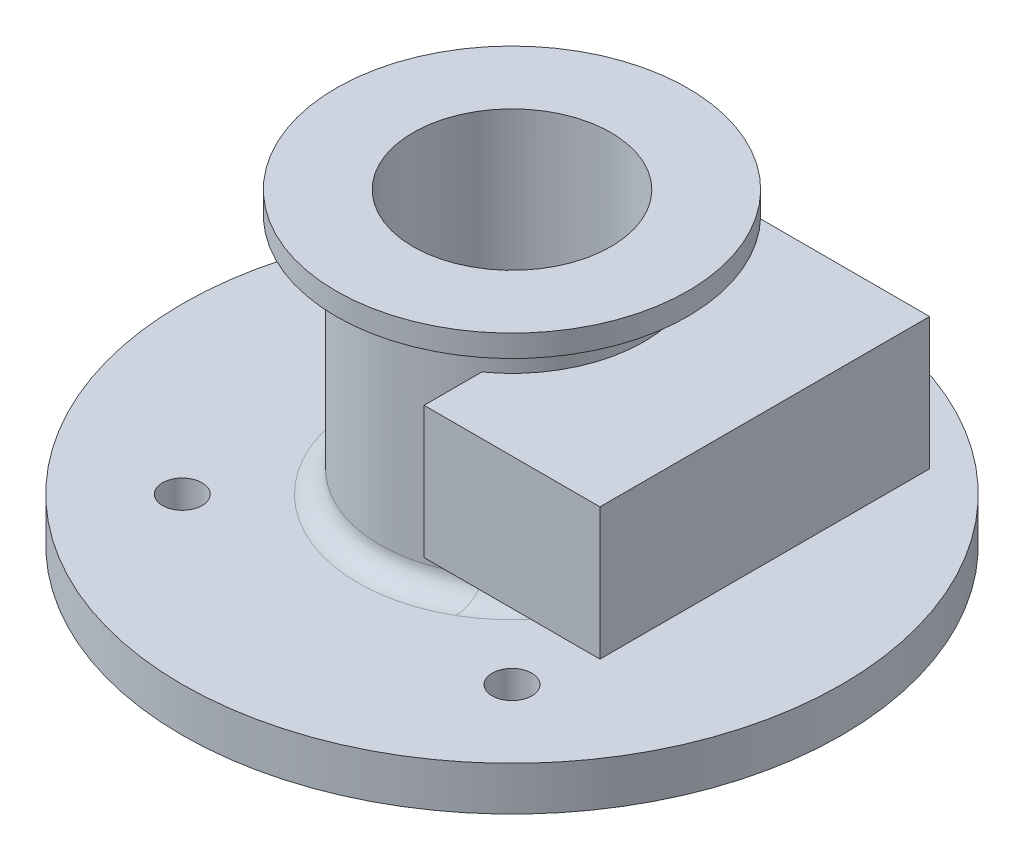
from build123d import *

# Parameters (mm, degrees)
SKETCH1_R           = 75
SKETCH1_R_2         = 4.5
BOSS_EXTRUDE1_DEPTH = 10
SKETCH2_R           = 30
BOSS_EXTRUDE2_DEPTH = 55
SKETCH3_R           = 40
BOSS_EXTRUDE3_DEPTH = 5
SKETCH4_R           = 22.5
CUT_EXTRUDE1_DEPTH  = 60
FILLET1_R           = 5
SKETCH5_W           = 40
SKETCH5_H           = 75
BOSS_EXTRUDE4_DEPTH = 45
CUT_EXTRUDE2_DEPTH  = 113.5
SKETCH7_R           = 30
BOSS_EXTRUDE5_DEPTH = 15
FILLET2_R           = 5
CUT_EXTRUDE3_DEPTH  = 45


with BuildPart() as part:
    # Sketch1 → Boss-Extrude1 (new body)
    with BuildSketch(Plane(origin=(0, 0, 0), x_dir=(1, 0, 0), z_dir=(0, 1, 0))):
        Circle(SKETCH1_R)
        with Locations((37.5, 37.5)):
            Circle(SKETCH1_R_2, mode=Mode.SUBTRACT)
        with Locations((-37.5, 37.5)):
            Circle(SKETCH1_R_2, mode=Mode.SUBTRACT)
        with Locations((-37.5, -37.5)):
            Circle(SKETCH1_R_2, mode=Mode.SUBTRACT)
        with Locations((37.5, -37.5)):
            Circle(SKETCH1_R_2, mode=Mode.SUBTRACT)
    extrude(amount=BOSS_EXTRUDE1_DEPTH)

    # Sketch2 → Boss-Extrude2 (add)
    with BuildSketch(Plane(origin=(0, 10, 0), x_dir=(1, 0, 0), z_dir=(0, 1, 0))):
        Circle(SKETCH2_R)
    extrude(amount=BOSS_EXTRUDE2_DEPTH)

    # Sketch3 → Boss-Extrude3 (add)
    with BuildSketch(Plane(origin=(0, 65, 0), x_dir=(1, 0, 0), z_dir=(0, 1, 0))):
        Circle(SKETCH3_R)
    extrude(amount=BOSS_EXTRUDE3_DEPTH)

    # Sketch4 → Cut-Extrude1 (cut)
    with BuildSketch(Plane(origin=(0, 70, 0), x_dir=(1, 0, 0), z_dir=(0, 1, 0))):
        Circle(SKETCH4_R)
    extrude(amount=-CUT_EXTRUDE1_DEPTH, mode=Mode.SUBTRACT)

    # Fillet1
    fillet1_edges = [part.edges().sort_by_distance(p)[0] for p in [
        (-30, 10, 0),
        (-30, 65, 0),
    ]]
    fillet(fillet1_edges, radius=FILLET1_R)

    # Sketch5 → Boss-Extrude4 (add)
    with BuildSketch(Plane(origin=(0, 10, 0), x_dir=(1, 0, 0), z_dir=(0, 1, 0))):
        with Locations((37.5, 0)):
            Rectangle(SKETCH5_W, SKETCH5_H)
    extrude(amount=BOSS_EXTRUDE4_DEPTH)

    # Sketch6 → Cut-Extrude2 (cut, through all)
    with BuildSketch(Plane.XY.offset(37.5)):
        Polygon((57.5, 25), (30, 25), (17.5, 25), (17.5, 10), (33, 10), (42, 10), (57.5, 10), align=None)
    extrude(amount=-CUT_EXTRUDE2_DEPTH, mode=Mode.SUBTRACT)

    # Sketch7 → Boss-Extrude5 (add)
    with BuildSketch(Plane(origin=(0, 10, 0), x_dir=(1, 0, 0), z_dir=(0, 1, 0))):
        Circle(SKETCH7_R)
    extrude(amount=BOSS_EXTRUDE5_DEPTH)

    # Fillet2
    fillet2_edges = [part.edges().sort_by_distance(p)[0] for p in [
        (26.69269563, 10, 13.693063938),
    ]]
    fillet(fillet2_edges, radius=FILLET2_R)

    # Sketch8 → Cut-Extrude3 (cut)
    with BuildSketch(Plane(origin=(0, 70, 0), x_dir=(1, 0, 0), z_dir=(0, 1, 0))):
        with BuildLine():
            ThreePointArc((17.5, 14.142135624), (-22.5, 0), (17.5, -14.142135624))
            ThreePointArc((17.5, -14.142135624), (22.5, 0), (17.5, 14.142135624))
        make_face()
    extrude(amount=-CUT_EXTRUDE3_DEPTH, mode=Mode.SUBTRACT)


solid = part.part
